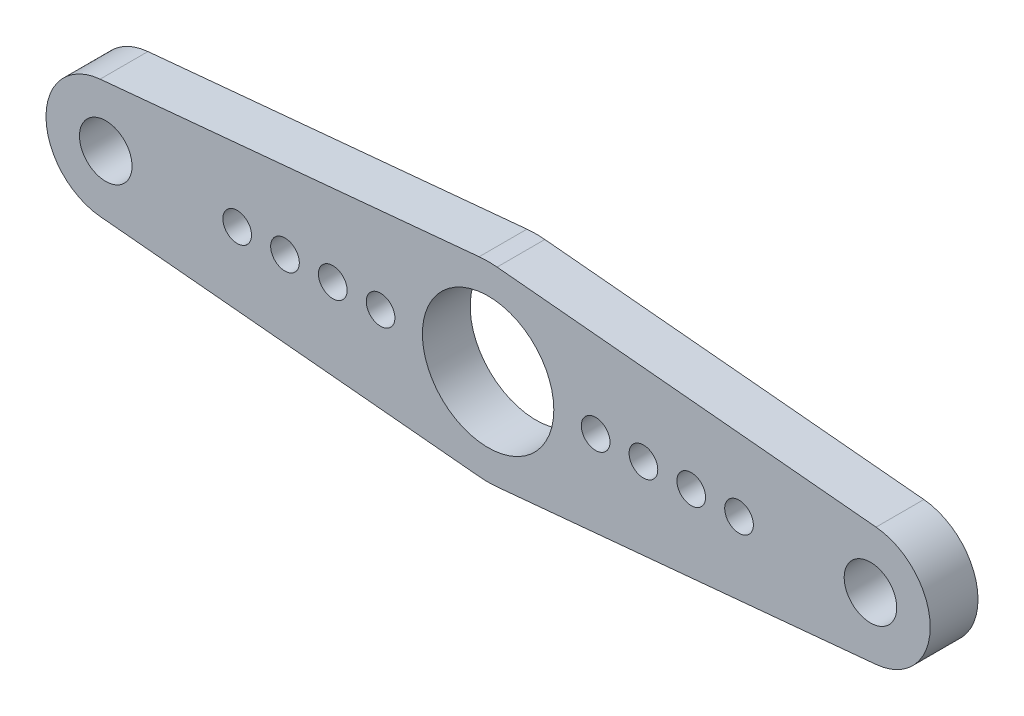
from build123d import *

# Parameters (mm, degrees)
EXTRUDE_1_DEPTH     = 2
SKETCH_2_R          = 2.75
SKETCH_2_R_2        = 1.1
SKETCH_2_R_3        = 0.6
CUT_EXTRUDE_1_DEPTH = 2


with BuildPart() as part:
    # 草图1 → 凸台-拉伸1 (new body)
    with BuildSketch(Plane.XY):
        with BuildLine():
            Line((-16.234375, 2.488989425), (-0.375, 3.982383081))
            ThreePointArc((-0.375, 3.982383081), (0, 4), (0.375, 3.982383081))
            Line((0.375, 3.982383081), (16.234375, 2.488989425))
            ThreePointArc((16.234375, 2.488989425), (18.5, 0), (16.234375, -2.488989425))
            Line((16.234375, -2.488989425), (0.375, -3.982383081))
            ThreePointArc((0.375, -3.982383081), (0, -4), (-0.375, -3.982383081))
            Line((-0.375, -3.982383081), (-16.234375, -2.488989425))
            ThreePointArc((-16.234375, -2.488989425), (-18.5, 0), (-16.234375, 2.488989425))
        make_face()
    extrude(amount=EXTRUDE_1_DEPTH)

    # 草图2 → 切除-拉伸1 (cut)
    with BuildSketch(Plane.XY.offset(2)):
        Circle(SKETCH_2_R)
        with Locations((-16, 0)):
            Circle(SKETCH_2_R_2)
        with Locations((16, 0)):
            Circle(SKETCH_2_R_2)
        with Locations((-4.5, 0)):
            Circle(SKETCH_2_R_3)
        with Locations((-6.5, 0)):
            Circle(SKETCH_2_R_3)
        with Locations((-8.5, 0)):
            Circle(SKETCH_2_R_3)
        with Locations((-10.5, 0)):
            Circle(SKETCH_2_R_3)
        with Locations((4.5, 0)):
            Circle(SKETCH_2_R_3)
        with Locations((10.5, 0)):
            Circle(SKETCH_2_R_3)
        with Locations((8.5, 0)):
            Circle(SKETCH_2_R_3)
        with Locations((6.5, 0)):
            Circle(SKETCH_2_R_3)
    extrude(amount=-CUT_EXTRUDE_1_DEPTH, mode=Mode.SUBTRACT)


solid = part.part
